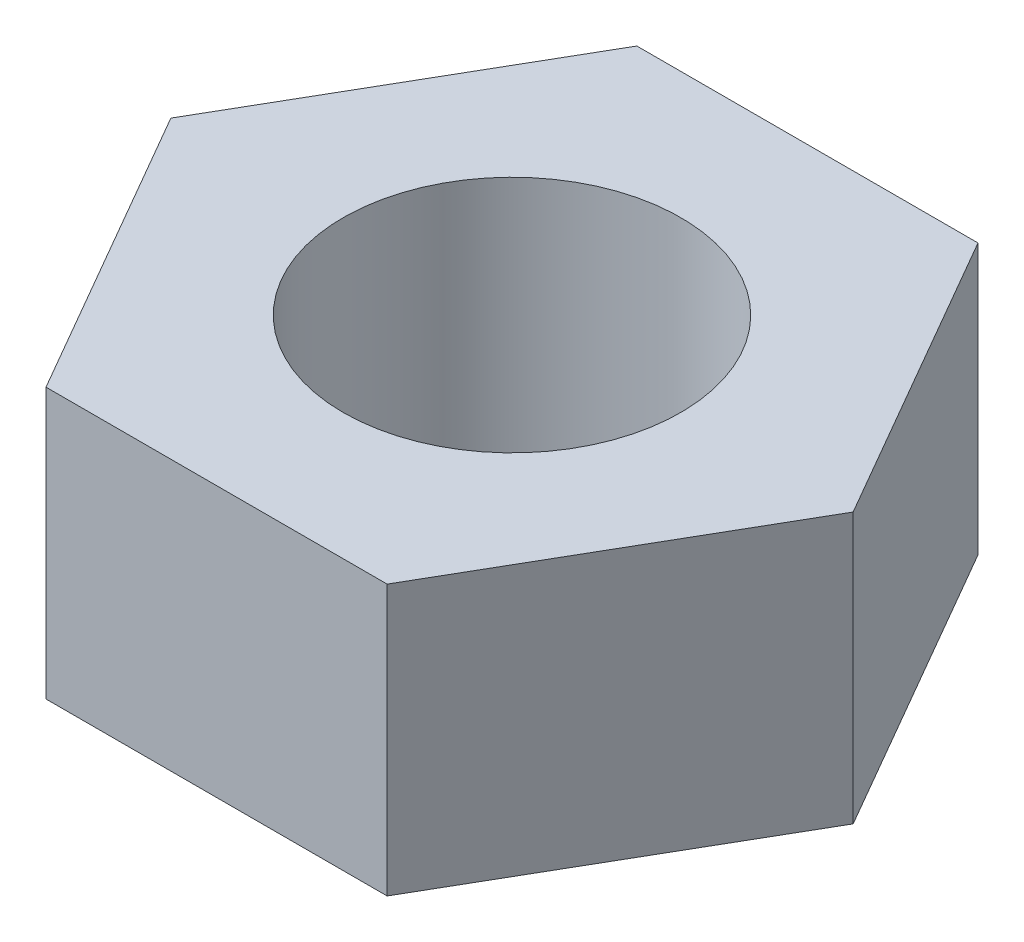
from build123d import *

# Parameters (mm, degrees)
SKETCH1_R           = 2
BOSS_EXTRUDE1_DEPTH = 3.2


with BuildPart() as part:
    # Sketch1 → Boss-Extrude1 (new body)
    with BuildSketch(Plane(origin=(0, 0, 0), x_dir=(1, 0, 0), z_dir=(0, 1, 0))):
        Polygon((2.020725942, -3.5), (4.041451884, 0), (2.020725942, 3.5), (-2.020725942, 3.5), (-4.041451884, 0), (-2.020725942, -3.5), align=None)
        Circle(SKETCH1_R, mode=Mode.SUBTRACT)
    extrude(amount=BOSS_EXTRUDE1_DEPTH)


solid = part.part
